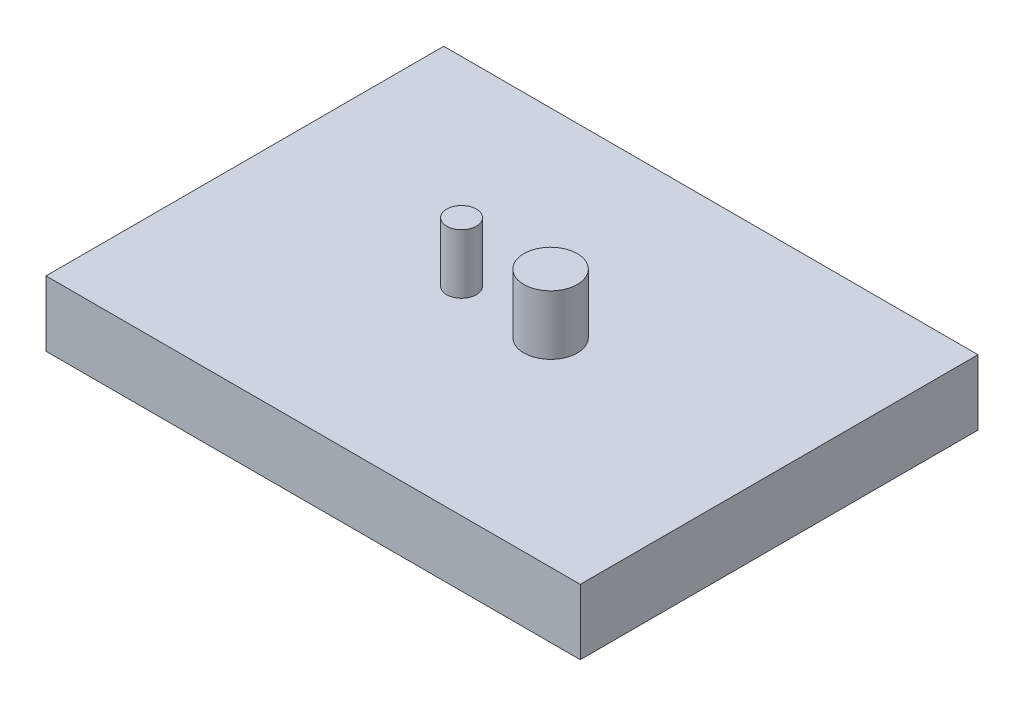
from build123d import *

# Parameters (mm, degrees)
SKETCH_1_W      = 90
SKETCH_1_H      = 67
EXTRUDE_1_DEPTH = 11
SKETCH_2_R      = 2.5
SKETCH_2_R_2    = 4.5
EXTRUDE_2_DEPTH = 10


with BuildPart() as part:
    # Эскиз1 → Бобышка-Вытянуть1 (new body)
    with BuildSketch(Plane(origin=(0, 0, 0), x_dir=(1, 0, 0), z_dir=(0, 1, 0))):
        with Locations((45, -33.5)):
            Rectangle(SKETCH_1_W, SKETCH_1_H)
    extrude(amount=EXTRUDE_1_DEPTH)

    # Эскиз2 → Бобышка-Вытянуть2 (add)
    with BuildSketch(Plane(origin=(0, 11, 0), x_dir=(1, 0, 0), z_dir=(0, 1, 0))):
        with Locations((36.5, -33.5)):
            Circle(SKETCH_2_R)
        with Locations((51.5, -33.5)):
            Circle(SKETCH_2_R_2)
    extrude(amount=EXTRUDE_2_DEPTH)


solid = part.part
